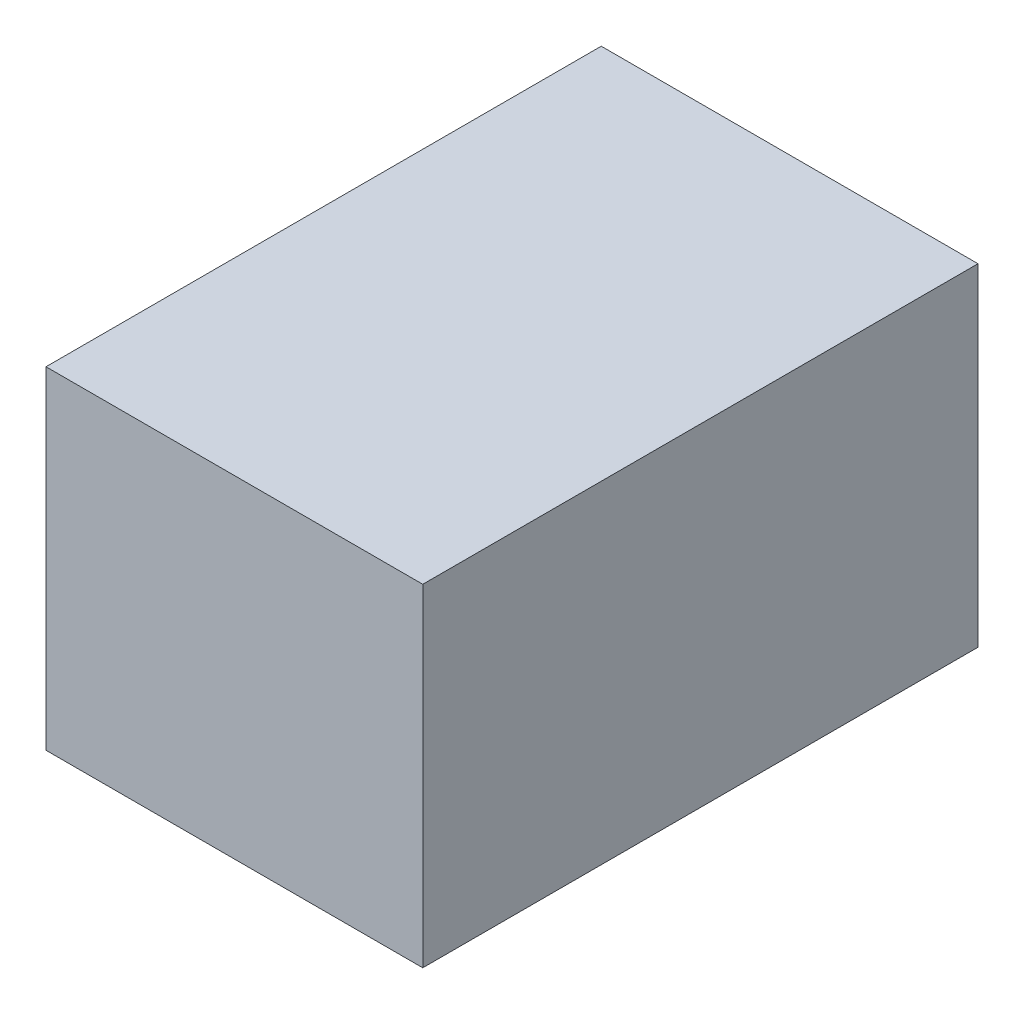
from build123d import *

# Parameters (mm, degrees)
SKETCH1_W           = 38
SKETCH1_H           = 33.5
BOSS_EXTRUDE1_DEPTH = 56


with BuildPart() as part:
    # Sketch1 → Boss-Extrude1 (new body)
    with BuildSketch(Plane.XY):
        Rectangle(SKETCH1_W, SKETCH1_H)
    extrude(amount=BOSS_EXTRUDE1_DEPTH)


solid = part.part
